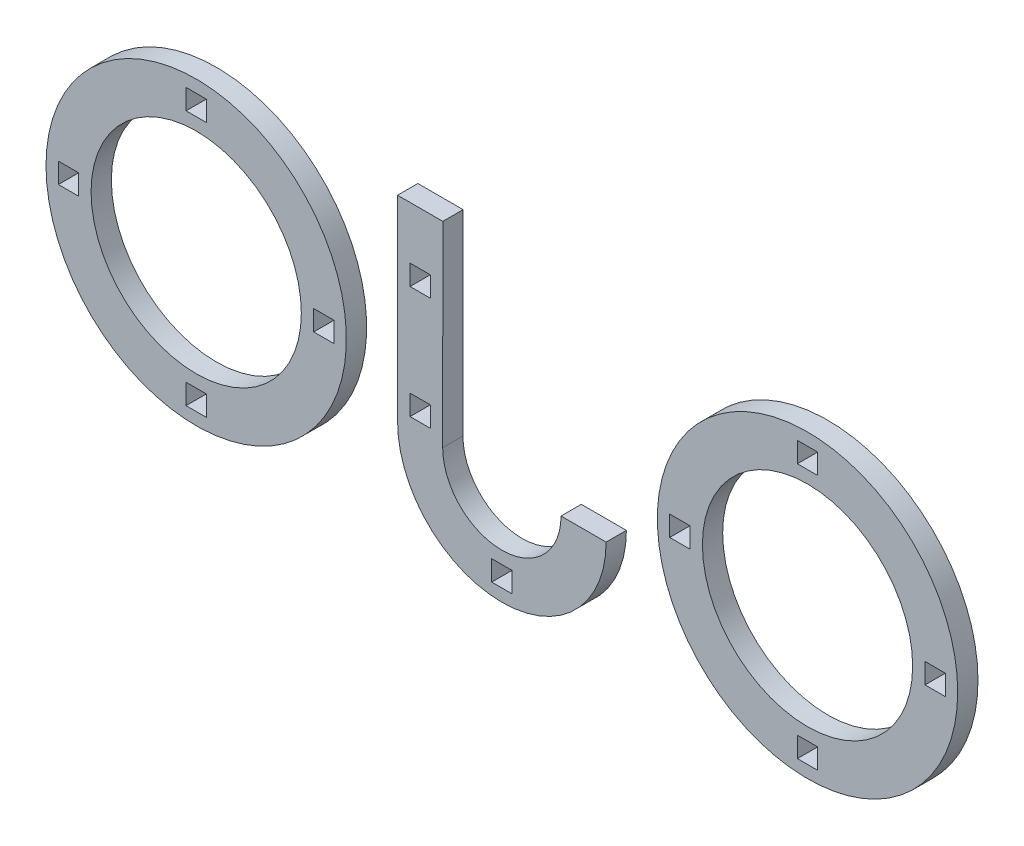
from build123d import *

# Parameters (mm, degrees)
SKETCH1_R             = 20
SKETCH1_R_2           = 14
SKETCH1_W             = 2.7
SKETCH1_H             = 2.7
BOSS_EXTRUDE3_DEPTH   = 2.7
BOSS_EXTRUDE3_2_DEPTH = 2.7
BOSS_EXTRUDE3_3_DEPTH = 2.7


with BuildPart() as part:
    # Sketch1 → Boss-Extrude3 (new body)
    with BuildSketch(Plane.XY):
        with Locations((48.332142187, 1.511416081)):
            Circle(SKETCH1_R)
        with Locations((48.332142187, 1.511416081)):
            Circle(SKETCH1_R_2, mode=Mode.SUBTRACT)
        with Locations((65.332142187, 1.511416081)):
            Rectangle(SKETCH1_W, SKETCH1_H, mode=Mode.SUBTRACT)
        with Locations((48.332142187, 18.511416081)):
            Rectangle(SKETCH1_W, SKETCH1_H, mode=Mode.SUBTRACT)
        with Locations((48.332142187, -15.488583919)):
            Rectangle(SKETCH1_W, SKETCH1_H, mode=Mode.SUBTRACT)
        with Locations((31.332142187, 1.511416081)):
            Rectangle(SKETCH1_W, SKETCH1_H, mode=Mode.SUBTRACT)
    extrude(amount=BOSS_EXTRUDE3_DEPTH)


with BuildPart() as body_2:
    # Sketch1 → Boss-Extrude3 2 (new body)
    with BuildSketch(Plane.XY):
        with Locations((-33.07519389, 1.511416081)):
            Circle(SKETCH1_R)
        with Locations((-33.07519389, 1.511416081)):
            Circle(SKETCH1_R_2, mode=Mode.SUBTRACT)
        with Locations((-16.07519389, 1.511416081)):
            Rectangle(SKETCH1_W, SKETCH1_H, mode=Mode.SUBTRACT)
        with Locations((-33.07519389, -15.488583919)):
            Rectangle(SKETCH1_W, SKETCH1_H, mode=Mode.SUBTRACT)
        with Locations((-33.07519389, 18.511416081)):
            Rectangle(SKETCH1_W, SKETCH1_H, mode=Mode.SUBTRACT)
        with Locations((-50.07519389, 1.511416081)):
            Rectangle(SKETCH1_W, SKETCH1_H, mode=Mode.SUBTRACT)
    extrude(amount=BOSS_EXTRUDE3_2_DEPTH)


with BuildPart() as body_3:
    # Sketch1 → Boss-Extrude3 3 (new body)
    with BuildSketch(Plane.XY):
        with BuildLine():
            Line((21.512673122, -4.602466422), (15.506554204, -4.602466422))
            ThreePointArc((15.506554204, -4.602466422), (7.62336958, -12.48246449), (-0.253440643, -4.596094597))
            Line((-0.253440643, -4.596094597), (-0.232329911, 21.511416082))
            Line((-0.232329911, 21.511416082), (-6.259562137, 21.511416082))
            Line((-6.259562137, 21.511416082), (-6.259562137, -4.602466422))
            ThreePointArc((-6.259562137, -4.602466422), (7.626555493, -18.488584051), (21.512673122, -4.602466422))
        make_face()
        with Locations((-3.245946024, -1.835659199)):
            Rectangle(SKETCH1_W, SKETCH1_H, mode=Mode.SUBTRACT)
        with Locations((-3.245946024, 13.164340801)):
            Rectangle(SKETCH1_W, SKETCH1_H, mode=Mode.SUBTRACT)
        with Locations((7.626555493, -15.485524593)):
            Rectangle(SKETCH1_W, SKETCH1_H, mode=Mode.SUBTRACT)
    extrude(amount=BOSS_EXTRUDE3_3_DEPTH)


solid = Compound([part.part, body_2.part, body_3.part])
